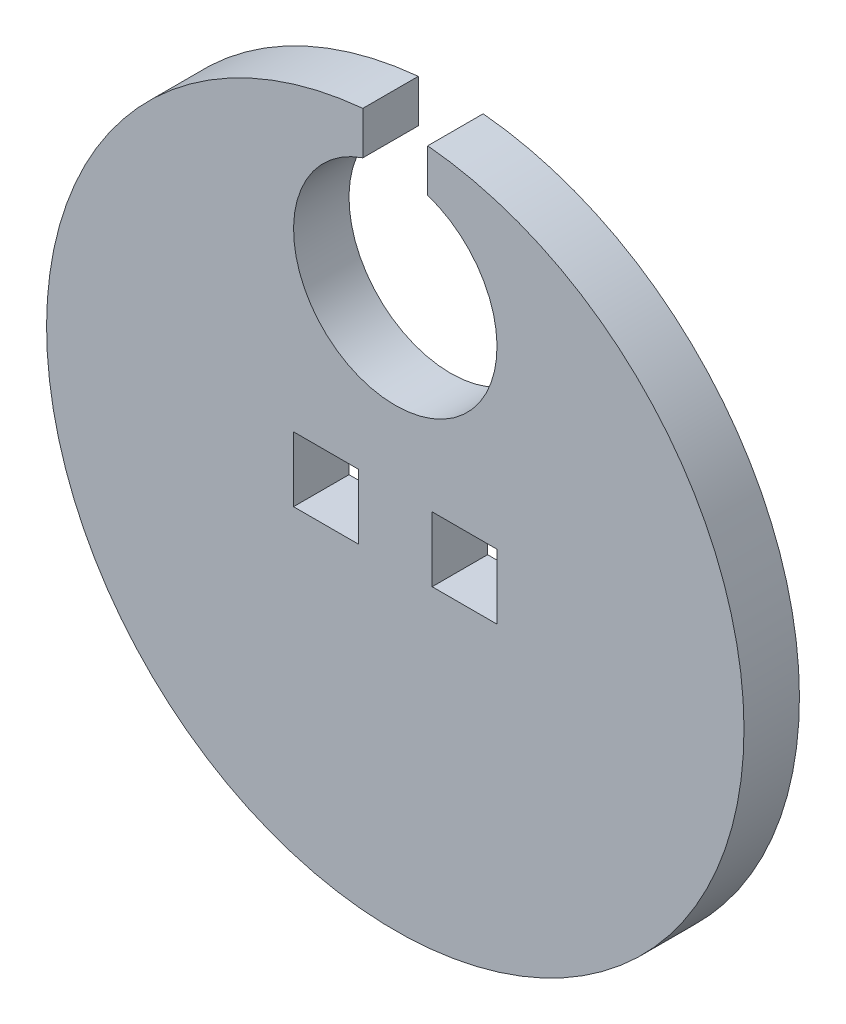
from build123d import *

# Parameters (mm, degrees)
SKETCH1_R           = 15.9766
SKETCH1_W           = 2.9718
SKETCH1_H           = 2.9718
BOSS_EXTRUDE1_DEPTH = 2.54
CUT_EXTRUDE1_DEPTH  = 2.54


with BuildPart() as part:
    # Sketch1 → Boss-Extrude1 (new body)
    with BuildSketch(Plane.XY):
        Circle(SKETCH1_R)
        with Locations((-3.175, 0)):
            Rectangle(SKETCH1_W, SKETCH1_H, mode=Mode.SUBTRACT)
        with Locations((3.175, 0)):
            Rectangle(SKETCH1_W, SKETCH1_H, mode=Mode.SUBTRACT)
    extrude(amount=BOSS_EXTRUDE1_DEPTH)

    # Sketch2 → Cut-Extrude1 (cut)
    with BuildSketch(Plane.XY.offset(2.54)):
        with BuildLine():
            Line((-1.4859, 13.942701891), (-1.4859, 18.9484))
            Line((-1.4859, 18.9484), (1.4859, 18.9484))
            Line((1.4859, 18.9484), (1.4859, 13.942701891))
            ThreePointArc((1.4859, 13.942701891), (0, 4.8641), (-1.4859, 13.942701891))
        make_face()
    extrude(amount=-CUT_EXTRUDE1_DEPTH, mode=Mode.SUBTRACT)


solid = part.part
